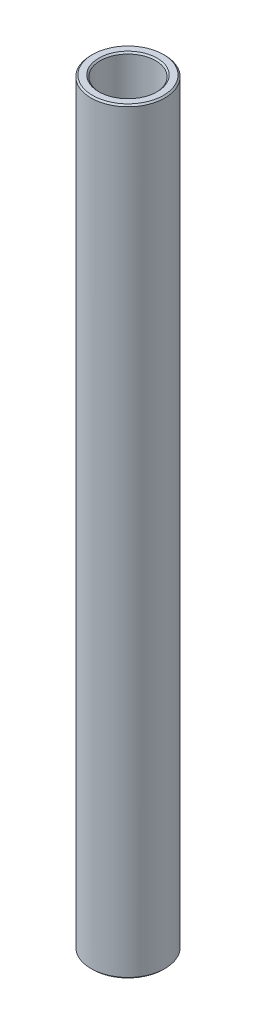
from build123d import *

# Parameters (mm, degrees)
SKETCH1_W     = 1.5875
SKETCH1_H     = 130.175
CHAMFER1_SIZE = 0.254


with BuildPart() as part:
    # Sketch1 → Revolve1 (revolve)
    with BuildSketch(Plane.XY):
        with Locations((5.55625, 0)):
            Rectangle(SKETCH1_W, SKETCH1_H)
    revolve(axis=Axis((0, 11.60859375, 0), (0, -1, 0)))

    # Chamfer1
    chamfer1_edges = [part.edges().sort_by_distance(p)[0] for p in [
        (-4.7625, -65.0875, 0),
        (-6.35, -65.0875, 0),
        (-6.35, 65.0875, 0),
        (-4.7625, 65.0875, 0),
    ]]
    chamfer(chamfer1_edges, length=CHAMFER1_SIZE)


solid = part.part
